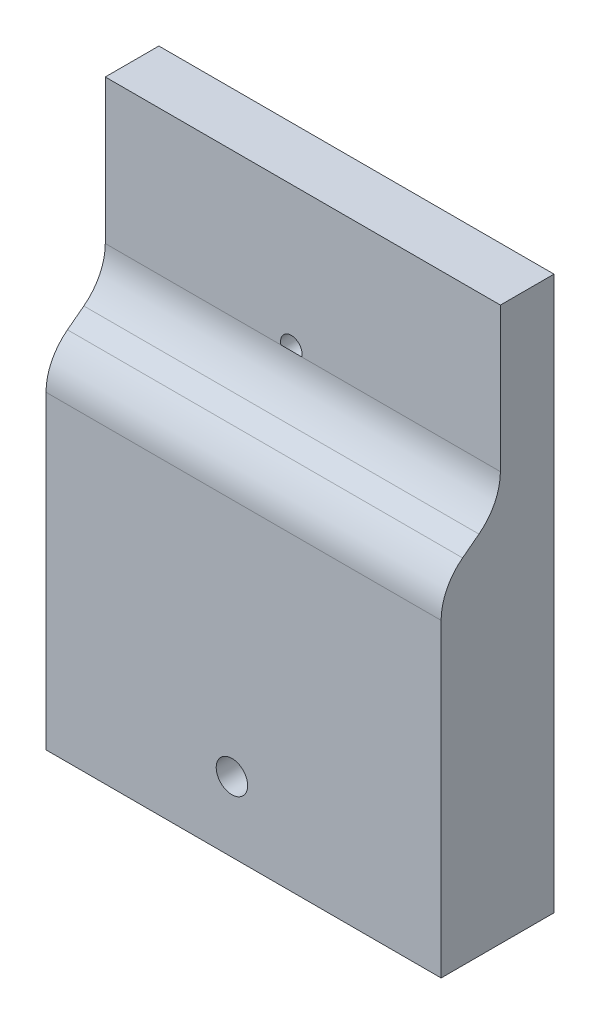
from build123d import *

# Parameters (mm, degrees)
SKETCH1_W                  = 63.5
SKETCH1_H                  = 88.9
BOSS_EXTRUDE1_DEPTH        = 18.13868
CUT_EXTRUDE1_DEPTH         = 63.5
SKETCH5_W                  = 1.7272
SKETCH5_H                  = 8.613680223
F_8_0_199_DIAMETER_HOLE1_D = 5.0546


with BuildPart() as part:
    # Sketch1 → Boss-Extrude1 (new body)
    with BuildSketch(Plane.XY):
        with Locations((-78.907526017, 47.538989794)):
            Rectangle(SKETCH1_W, SKETCH1_H)
    extrude(amount=BOSS_EXTRUDE1_DEPTH)

    # Sketch2 → Cut-Extrude1 (cut)
    with BuildSketch(Plane.ZY.offset(110.657526017)):
        with BuildLine():
            Line((8.613680223, 91.988989794), (8.613680223, 74.018491939))
            Line((8.613680223, 74.018491939), (8.613680223, 69.243291939))
            Line((8.613680223, 69.243291939), (8.613680223, 68.805550488))
            ThreePointArc((8.613680223, 68.805550488), (8.619201776, 68.494519524), (8.635759479, 68.183880521))
            ThreePointArc((8.635759479, 68.183880521), (9.666013904, 64.641922993), (12.0625652, 61.83774233))
            Line((12.0625652, 61.83774233), (13.078006955, 61.063298751))
            Line((13.078006955, 61.063298751), (13.67435349, 60.608485127))
            Line((13.67435349, 60.608485127), (14.689795245, 59.834041549))
            ThreePointArc((14.689795245, 59.834041549), (17.086346542, 57.029860886), (18.116600967, 53.487903358))
            ThreePointArc((18.116600967, 53.487903358), (18.133158669, 53.177264354), (18.138680223, 52.866233391))
            Line((18.138680223, 52.866233391), (18.138680223, 91.988989794))
            Line((18.138680223, 91.988989794), (8.613680223, 91.988989794))
        make_face()
    extrude(amount=-CUT_EXTRUDE1_DEPTH, mode=Mode.SUBTRACT)

    # Sketch5 → #29 (0.136) Diameter Hole1 (revolve, cut)
    with BuildSketch(Plane(origin=(-80.764740239, 69.243291939, 8.613680223), x_dir=(0, -1, 0), z_dir=(1, 0, 0))):
        with Locations((0.8636, 4.306840112)):
            Rectangle(SKETCH5_W, SKETCH5_H)
    revolve(axis=Axis((-80.764740239, 69.243291939, 14.963680223), (0, 0, -1)), mode=Mode.SUBTRACT)

    # #8 (0.199) Diameter Hole1 (through all)
    with Locations(Plane.XY.offset(18.138680223)):
        with Locations((-80.777440239, 14.315791939)):
            Hole(F_8_0_199_DIAMETER_HOLE1_D / 2)


solid = part.part
